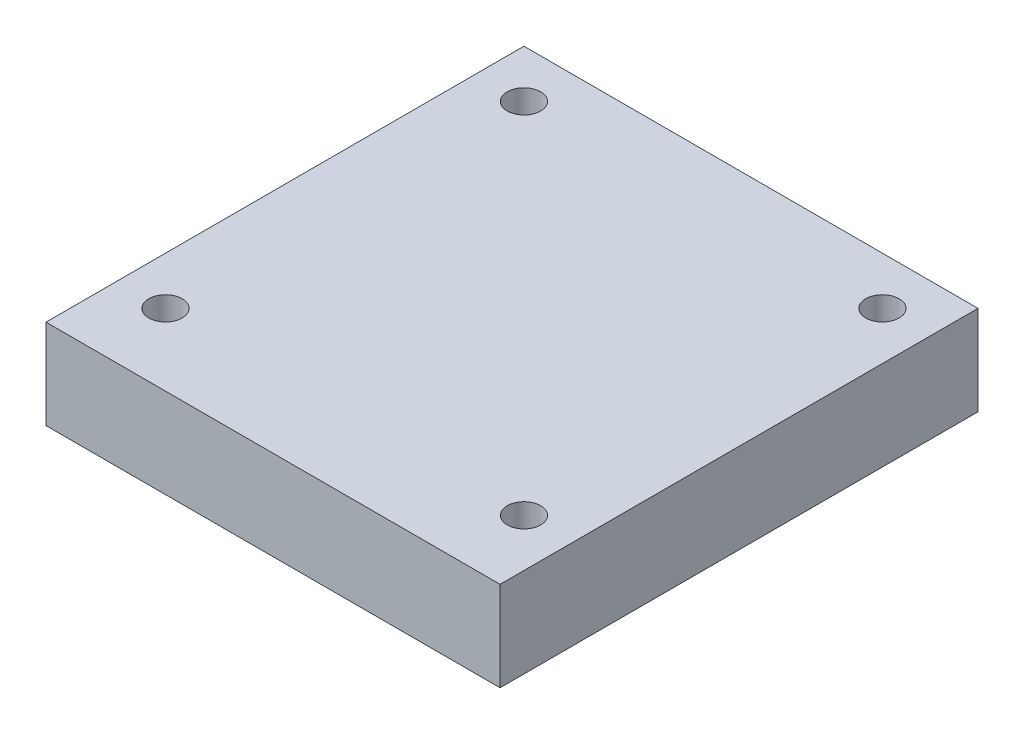
from build123d import *

# Parameters (mm, degrees)
SKETCH1_W           = 38
SKETCH1_H           = 40
SKETCH1_R           = 1.397916054
BOSS_EXTRUDE1_DEPTH = 7.5


with BuildPart() as part:
    # Sketch1 → Boss-Extrude1 (new body)
    with BuildSketch(Plane(origin=(0, 0, 0), x_dir=(1, 0, 0), z_dir=(0, 1, 0))):
        with Locations((19, 20)):
            Rectangle(SKETCH1_W, SKETCH1_H)
        with Locations((4, 36)):
            Circle(SKETCH1_R, mode=Mode.SUBTRACT)
        with Locations((34, 36)):
            Circle(SKETCH1_R, mode=Mode.SUBTRACT)
        with Locations((4, 6)):
            Circle(SKETCH1_R, mode=Mode.SUBTRACT)
        with Locations((34, 6)):
            Circle(SKETCH1_R, mode=Mode.SUBTRACT)
    extrude(amount=BOSS_EXTRUDE1_DEPTH)


solid = part.part
